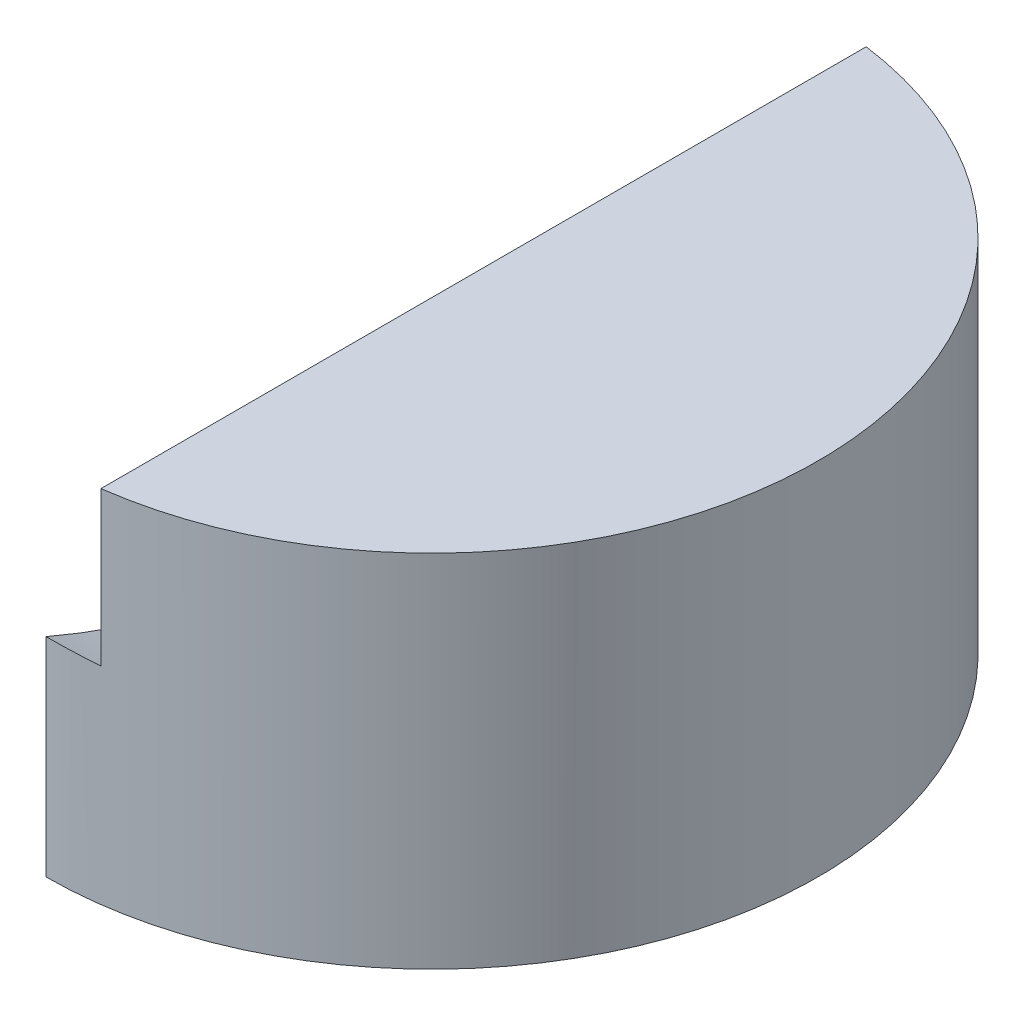
from build123d import *

# Parameters (mm, degrees)
BOSS_EXTRUDE2_DEPTH = 100
SKETCH3_W           = 11
SKETCH3_H           = 22
SKETCH4_R           = 1
CUT_EXTRUDE1_DEPTH  = 2
SKETCH5_R           = 1
CUT_EXTRUDE2_DEPTH  = 2
CIRPATTERN1_COUNT   = 4
SKETCH6_W           = 10
SKETCH6_H           = 190
BOSS_EXTRUDE4_DEPTH = 115
SKETCH10_W          = 10
SKETCH10_H          = 190
SKETCH11_R          = 1
CUT_EXTRUDE3_DEPTH  = 2
SKETCH8_R           = 2.5
SKETCH8_W           = 20
SKETCH8_H           = 5
CUT_EXTRUDE4_DEPTH  = 10
SKETCH12_R          = 75
CUT_EXTRUDE5_DEPTH  = 30


with BuildPart() as part:
    # Sketch1 → Boss-Extrude2 (new body)
    with BuildSketch(Plane(origin=(0, 0, 0), x_dir=(1, 0, 0), z_dir=(0, 1, 0))):
        with BuildLine():
            ThreePointArc((75, 0), (53.033008589, 53.033008589), (0, 75))
            Line((0, 75), (0, -75))
            ThreePointArc((0, -75), (53.033008589, -53.033008589), (75, 0))
        make_face()
    extrude(amount=BOSS_EXTRUDE2_DEPTH)

    # Sketch3 → Cut-Revolve3 (revolve, cut)
    with BuildSketch(Plane(origin=(0, 0, 0), x_dir=(-1, 0, 0), z_dir=(0, -1, 0))):
        with Locations((-59.5, 11)):
            Rectangle(SKETCH3_W, SKETCH3_H)
    cut_revolve3 = revolve(axis=Axis((0, 0, 0), (1, 0, 0)), mode=Mode.SUBTRACT)

    # Sketch4 → Cut-Extrude1 (cut)
    with BuildSketch(Plane.ZY.offset(-65)):
        Circle(SKETCH4_R)
    cut_extrude1 = extrude(amount=-CUT_EXTRUDE1_DEPTH, mode=Mode.SUBTRACT)

    # Sketch5 → Cut-Extrude2 (cut)
    with BuildSketch(Plane(origin=(54, 0, 0), x_dir=(0, 0, -1), z_dir=(1, 0, 0))):
        Circle(SKETCH5_R)
    cut_extrude2 = extrude(amount=-CUT_EXTRUDE2_DEPTH, mode=Mode.SUBTRACT)

    # CirPattern1: Cut-Revolve3, Cut-Extrude1, Cut-Extrude2 ×4 about axis
    cirpattern1_axis = Axis((0, 0, 0), (0, 1, 0))
    add([cut_revolve3.rotate(cirpattern1_axis, i * 360 / CIRPATTERN1_COUNT) for i in range(1, CIRPATTERN1_COUNT)], mode=Mode.SUBTRACT)
    add([cut_extrude1.rotate(cirpattern1_axis, i * 360 / CIRPATTERN1_COUNT) for i in range(1, CIRPATTERN1_COUNT)], mode=Mode.SUBTRACT)
    add([cut_extrude2.rotate(cirpattern1_axis, i * 360 / CIRPATTERN1_COUNT) for i in range(1, CIRPATTERN1_COUNT)], mode=Mode.SUBTRACT)

    # Sketch6 → Boss-Extrude4 (add)
    with BuildSketch(Plane(origin=(0, 100, 0), x_dir=(1, 0, 0), z_dir=(0, 1, 0))):
        with Locations((5, -95)):
            Rectangle(SKETCH6_W, SKETCH6_H)
    extrude(amount=BOSS_EXTRUDE4_DEPTH)

    # Sketch10 → Cut-Revolve4 (revolve, cut)
    with BuildSketch(Plane(origin=(0, 215, 0), x_dir=(1, 0, 0), z_dir=(0, 1, 0))):
        with Locations((5, -95)):
            Rectangle(SKETCH10_W, SKETCH10_H)
    revolve(axis=Axis((10, 215, 0), (-1, 0, 0)), mode=Mode.SUBTRACT)


with BuildPart() as cut_revolve4_kept_piece:
    # of the separate pieces the step leaves, the one the design keeps (cut_revolve4_pieces_kept)
    add(part.part.solids().sort_by_distance((0, 0, 75))[0])

    # Sketch11 → Cut-Extrude3 (cut)
    with BuildSketch(Plane.ZY.offset(-10)):
        with Locations((-0.669656263, 47.5)):
            Circle(SKETCH11_R)
        with Locations((-65.669656263, 60.5)):
            Circle(SKETCH11_R)
        with Locations((64.330343737, 60.5)):
            Circle(SKETCH11_R)
    extrude(amount=-CUT_EXTRUDE3_DEPTH, mode=Mode.SUBTRACT)

    # Sketch8 → Cut-Extrude4 (cut)
    with BuildSketch(Plane.ZY):
        with Locations((-70, 10)):
            Circle(SKETCH8_R)
        with Locations(Location((70, 10, 0), (0, 0, 180))):
            Circle(SKETCH8_R)
        with Locations((-30, 2.5)):
            Rectangle(SKETCH8_W, SKETCH8_H)
        with Locations((30, 2.5)):
            Rectangle(SKETCH8_W, SKETCH8_H)
    extrude(amount=-CUT_EXTRUDE4_DEPTH, mode=Mode.SUBTRACT)

    # Sketch12 → Cut-Extrude5 (cut)
    with BuildSketch(Plane(origin=(0, 100, 0), x_dir=(1, 0, 0), z_dir=(0, 1, 0))):
        Circle(SKETCH12_R)
    extrude(amount=-CUT_EXTRUDE5_DEPTH, mode=Mode.SUBTRACT)


solid = cut_revolve4_kept_piece.part
